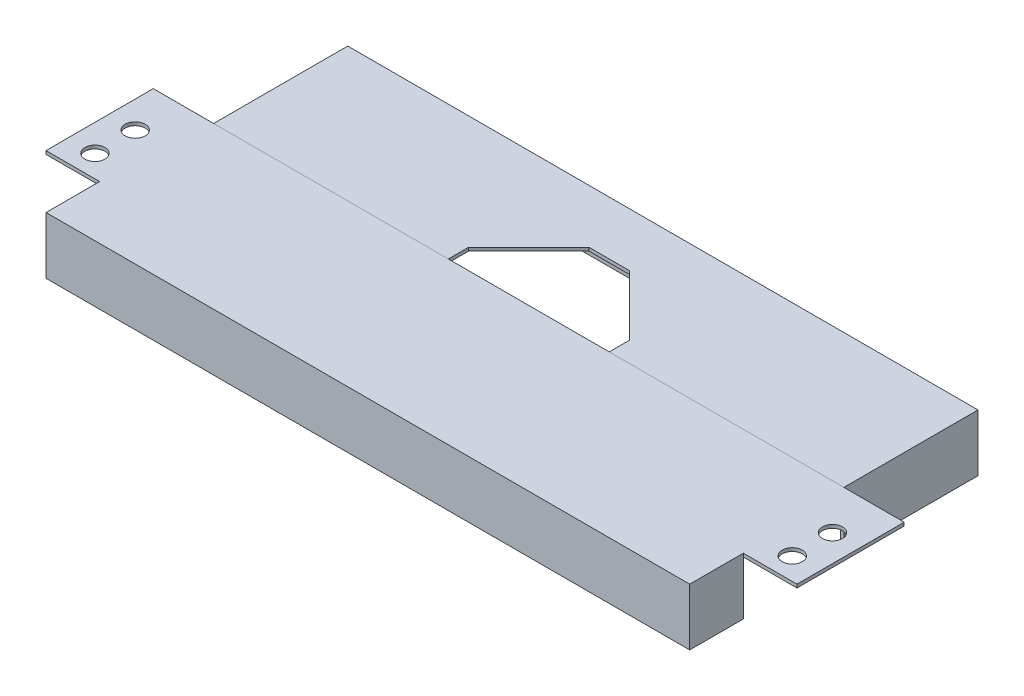
from build123d import *

# Parameters (mm, degrees)
BOSS_EXTRUDE1_DEPTH = 3.175
CHAMFER1_SIZE       = 57.15
SKETCH2_W           = 3.175
SKETCH2_H           = 127
BOSS_EXTRUDE2_DEPTH = 50.8
SKETCH3_W           = 3.175
SKETCH3_H           = 127
BOSS_EXTRUDE3_DEPTH = 50.8
BOSS_EXTRUDE4_DEPTH = 101.6
SKETCH5_W           = 609.6
SKETCH5_H           = 3.175
BOSS_EXTRUDE5_DEPTH = 50.8
BOSS_EXTRUDE6_DEPTH = 50.8
SKETCH7_W           = 590.55
SKETCH7_H           = 3.175
BOSS_EXTRUDE7_DEPTH = 50.8
SKETCH8_R           = 9.525
CUT_EXTRUDE1_DEPTH  = 54.975


with BuildPart() as part:
    # Sketch1 → Boss-Extrude1 (new body)
    with BuildSketch(Plane(origin=(0, 0, 0), x_dir=(1, 0, 0), z_dir=(0, 1, 0))):
        Polygon((222.25, 0), (222.25, 76.2), (374.65, 76.2), (374.65, 0), (596.9, 0), (596.9, 127), (0, 127), (0, 0), align=None)
    extrude(amount=BOSS_EXTRUDE1_DEPTH)

    # Chamfer1
    chamfer1_edges = [part.edges().sort_by_distance(p)[0] for p in [
        (374.65, 1.5875, -76.2),
        (222.25, 1.5875, -76.2),
    ]]
    chamfer(chamfer1_edges, length=CHAMFER1_SIZE)

    # Sketch3 → Boss-Extrude3 (add)
    with BuildSketch(Plane(origin=(0, 0, 0), x_dir=(-1, 0, 0), z_dir=(0, -1, 0))):
        with Locations((-595.3125, 63.5)):
            Rectangle(SKETCH3_W, SKETCH3_H)
    extrude(amount=BOSS_EXTRUDE3_DEPTH)


with BuildPart() as body_2:
    # Sketch2 → Boss-Extrude2 (new body)
    with BuildSketch(Plane(origin=(0, 0, 0), x_dir=(-1, 0, 0), z_dir=(0, -1, 0))):
        with Locations((-1.5875, 63.5)):
            Rectangle(SKETCH2_W, SKETCH2_H)
    extrude(amount=BOSS_EXTRUDE2_DEPTH)


with BuildPart() as body_3:
    # Sketch4 → Boss-Extrude4 (new body)
    with BuildSketch(Plane.XY):
        Polygon((0, 3.175), (-57.15, 3.175), (-57.15, 0), (0, 0), (596.9, 0), (654.05, 0), (654.05, 3.175), (596.9, 3.175), align=None)
    extrude(amount=BOSS_EXTRUDE4_DEPTH)



with BuildPart() as body_4:
    # Sketch5 → Boss-Extrude5 (new body)
    with BuildSketch(Plane.XY.offset(101.6)):
        with Locations((298.45, 1.5875)):
            Rectangle(SKETCH5_W, SKETCH5_H)
    extrude(amount=BOSS_EXTRUDE5_DEPTH)


with BuildPart() as body_3_1:
    add(body_3.part)

    add(body_4.part)  # Boss-Extrude6 merges body 4
    # Sketch6 → Boss-Extrude6 (add)
    with BuildSketch(Plane(origin=(0, 0, 0), x_dir=(-1, 0, 0), z_dir=(0, -1, 0))):
        Polygon((-603.25, -101.6), (-600.075, -101.6), (-600.075, -149.225), (3.175, -149.225), (3.175, -101.6), (6.35, -101.6), (6.35, -152.4), (-603.25, -152.4), align=None)
    extrude(amount=BOSS_EXTRUDE6_DEPTH)

    # Sketch8 → Cut-Extrude1 (cut, through all)
    with BuildSketch(Plane(origin=(0, 3.175, 0), x_dir=(1, 0, 0), z_dir=(0, 1, 0))):
        with Locations((-31.75, -80.645)):
            Circle(SKETCH8_R)
        with Locations((-31.75, -42.545)):
            Circle(SKETCH8_R)
        with Locations((628.65, -42.545)):
            Circle(SKETCH8_R)
        with Locations((628.65, -80.645)):
            Circle(SKETCH8_R)
    extrude(amount=-CUT_EXTRUDE1_DEPTH, mode=Mode.SUBTRACT)


with BuildPart() as body_4_2:
    # Sketch7 → Boss-Extrude7 (new body)
    with BuildSketch(Plane.XZ):
        with Locations((298.45, -125.4125)):
            Rectangle(SKETCH7_W, SKETCH7_H)
    extrude(amount=BOSS_EXTRUDE7_DEPTH)


solid = Compound([part.part, body_2.part, body_3_1.part, body_4_2.part])
